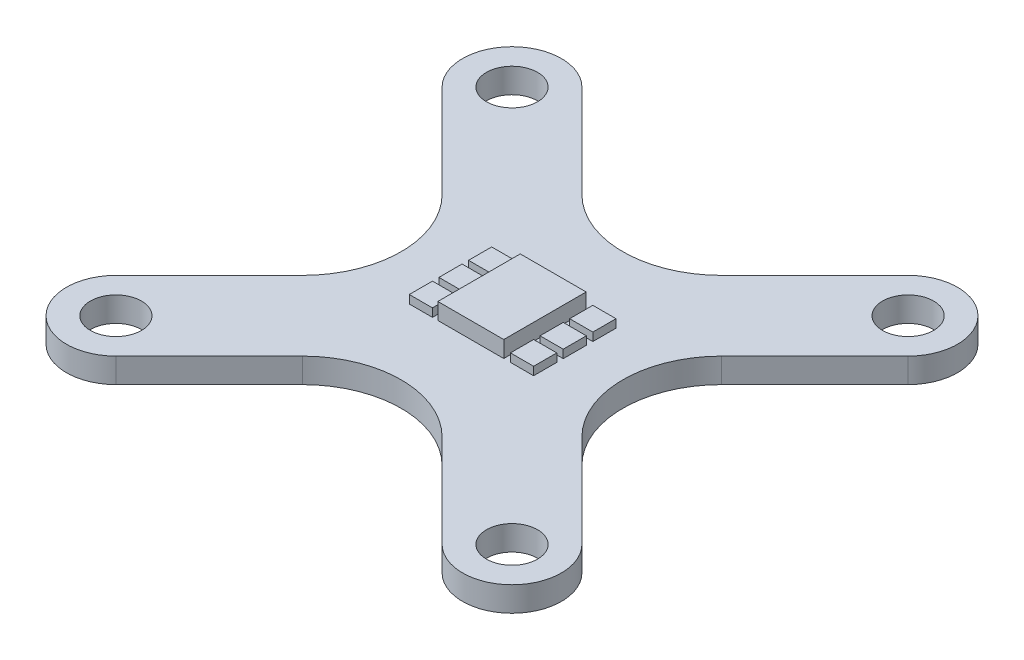
from build123d import *

# Parameters (mm, degrees)
SKETCH1_R           = 1.55
BOSS_EXTRUDE1_DEPTH = 1.5
FILLET1_R           = 6
SKETCH2_W           = 4
SKETCH2_H           = 5
BOSS_EXTRUDE2_DEPTH = 1
SKETCH3_W           = 1.405588528
SKETCH3_H           = 1.405588528
BOSS_EXTRUDE3_DEPTH = 0.5


with BuildPart() as part:
    # Sketch1 → Boss-Extrude1 (new body)
    with BuildSketch(Plane(origin=(0, 0, 0), x_dir=(1, 0, 0), z_dir=(0, 1, 0))):
        with BuildLine():
            Line((9.898679656, 14.141320344), (0, 4.242640687))
            Line((0, 4.242640687), (4.242640687, 0))
            Line((4.242640687, 0), (14.141320344, 9.898679656))
            ThreePointArc((14.141320344, 9.898679656), (14.141320344, 14.141320344), (9.898679656, 14.141320344))
        make_face()
        with Locations((12.02, 12.02)):
            Circle(SKETCH1_R, mode=Mode.SUBTRACT)
        with BuildLine():
            Line((-14.141320344, 9.898679656), (-4.242640687, 0))
            Line((-4.242640687, 0), (0, 4.242640687))
            Line((0, 4.242640687), (-9.898679656, 14.141320344))
            ThreePointArc((-9.898679656, 14.141320344), (-14.141320344, 14.141320344), (-14.141320344, 9.898679656))
        make_face()
        with Locations((-12.02, 12.02)):
            Circle(SKETCH1_R, mode=Mode.SUBTRACT)
        Polygon((0, 4.242640687), (-4.242640687, 0), (0, -4.242640687), (4.242640687, 0), align=None)
        with BuildLine():
            Line((4.242640687, 0), (0, -4.242640687))
            Line((0, -4.242640687), (9.898679656, -14.141320344))
            ThreePointArc((9.898679656, -14.141320344), (14.141320344, -14.141320344), (14.141320344, -9.898679656))
            Line((14.141320344, -9.898679656), (4.242640687, 0))
        make_face()
        with Locations((12.02, -12.02)):
            Circle(SKETCH1_R, mode=Mode.SUBTRACT)
        with BuildLine():
            Line((-4.242640687, 0), (-14.141320344, -9.898679656))
            ThreePointArc((-14.141320344, -9.898679656), (-14.141320344, -14.141320344), (-9.898679656, -14.141320344))
            Line((-9.898679656, -14.141320344), (0, -4.242640687))
            Line((0, -4.242640687), (-4.242640687, 0))
        make_face()
        with Locations((-12.02, -12.02)):
            Circle(SKETCH1_R, mode=Mode.SUBTRACT)
    extrude(amount=BOSS_EXTRUDE1_DEPTH)

    # Fillet1
    fillet1_edges = [part.edges().sort_by_distance(p)[0] for p in [
        (4.242640687, 0.75, 0),
        (0, 0.75, 4.242640687),
        (-4.242640687, 0.75, 0),
        (0, 0.75, -4.242640687),
    ]]
    fillet(fillet1_edges, radius=FILLET1_R)

    # Sketch2 → Boss-Extrude2 (add)
    with BuildSketch(Plane(origin=(0, 1.5, 0), x_dir=(1, 0, 0), z_dir=(0, 1, 0))):
        Rectangle(SKETCH2_W, SKETCH2_H)
    extrude(amount=BOSS_EXTRUDE2_DEPTH)

    # Sketch3 → Boss-Extrude3 (add)
    with BuildSketch(Plane(origin=(0, 1.5, 0), x_dir=(1, 0, 0), z_dir=(0, 1, 0))):
        with Locations((-3.030370202, -1.797205736)):
            Rectangle(SKETCH3_W, SKETCH3_H)
        with Locations((-3.030370202, 0)):
            Rectangle(SKETCH3_W, SKETCH3_H)
        with Locations((-3.030370202, 1.797205736)):
            Rectangle(SKETCH3_W, SKETCH3_H)
        with Locations((3.108126605, 0)):
            Rectangle(SKETCH3_W, SKETCH3_H)
        with Locations((3.108126605, -1.797205736)):
            Rectangle(SKETCH3_W, SKETCH3_H)
        with Locations((3.108126605, 1.797205736)):
            Rectangle(SKETCH3_W, SKETCH3_H)
    extrude(amount=BOSS_EXTRUDE3_DEPTH)


solid = part.part
